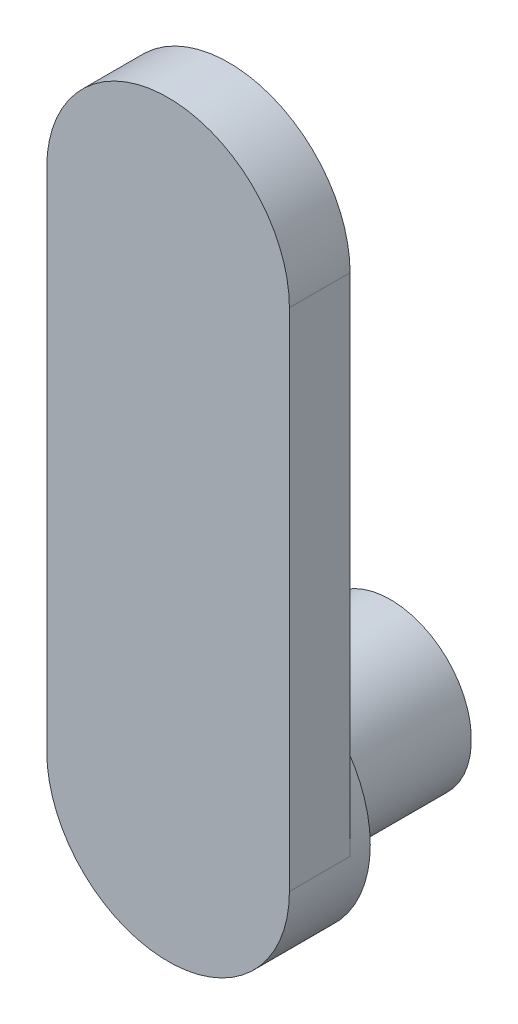
from build123d import *

# Parameters (mm, degrees)
SKETCH1_R           = 6
BOSS_EXTRUDE1_DEPTH = 1
BOSS_EXTRUDE2_DEPTH = 3
SKETCH3_R           = 4
BOSS_EXTRUDE3_DEPTH = 7


with BuildPart() as part:
    # Sketch1 → Boss-Extrude1 (new body)
    with BuildSketch(Plane.XY):
        Circle(SKETCH1_R)
    extrude(amount=-BOSS_EXTRUDE1_DEPTH)

    # Sketch2 → Boss-Extrude2 (add)
    with BuildSketch(Plane.XY):
        with BuildLine():
            Line((-6, 0), (-6, 25))
            ThreePointArc((-6, 25), (0, 31), (6, 25))
            Line((6, 25), (6, 0))
            ThreePointArc((6, 0), (0, -6), (-6, 0))
        make_face()
    extrude(amount=BOSS_EXTRUDE2_DEPTH)

    # Sketch3 → Boss-Extrude3 (add)
    with BuildSketch(Plane(origin=(0, 0, -1), x_dir=(-1, 0, 0), z_dir=(0, 0, -1))):
        Circle(SKETCH3_R)
    extrude(amount=BOSS_EXTRUDE3_DEPTH)


solid = part.part
